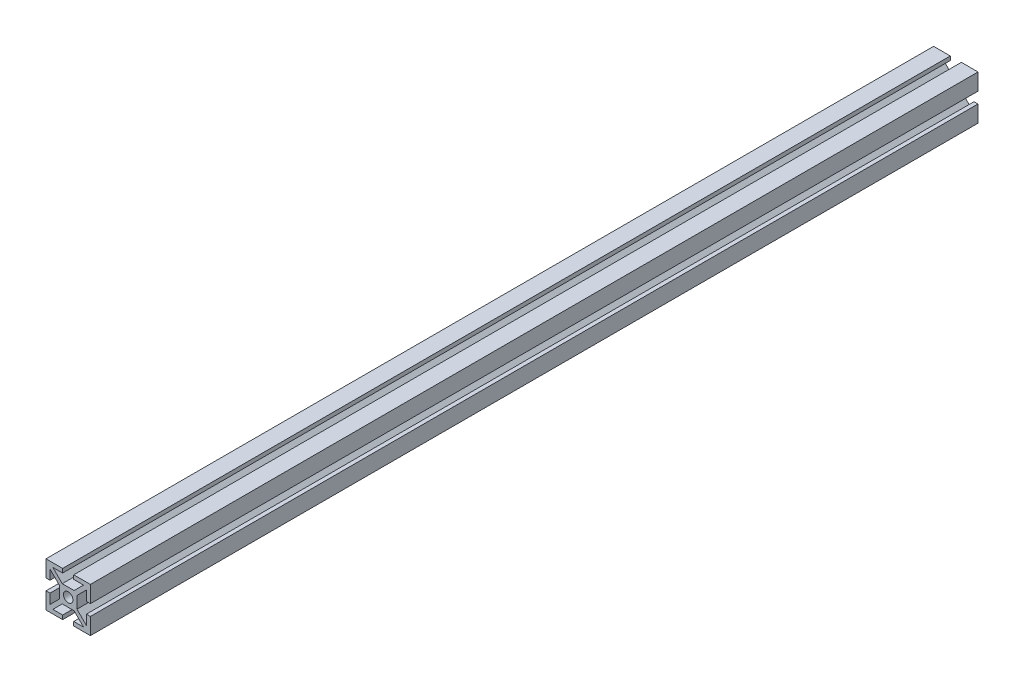
from build123d import *

# Parameters (mm, degrees)
SKETCH2_R           = 2.15
BOSS_EXTRUDE1_DEPTH = 200


with BuildPart() as part:
    # Sketch2 → Boss-Extrude1 (new body, symmetric)
    with BuildSketch(Plane.XY):
        Polygon((-2.5, 10), (-2.5, 8.2), (-6.927207794, 8.2), (-2.677207794, 3.95), (2.677207794, 3.95), (6.927207794, 8.2), (2.5, 8.2), (2.5, 10), (10, 10), (10, 2.5), (8.2, 2.5), (8.2, 6.927207794), (3.95, 2.677207794), (3.95, -2.677207794), (8.2, -6.927207794), (8.2, -2.5), (10, -2.5), (10, -10), (2.5, -10), (2.5, -8.2), (6.927207794, -8.2), (2.677207794, -3.95), (-2.677207794, -3.95), (-6.927207794, -8.2), (-2.5, -8.2), (-2.5, -10), (-10, -10), (-10, -2.5), (-8.2, -2.5), (-8.2, -6.927207794), (-3.95, -2.677207794), (-3.95, 2.677207794), (-8.2, 6.927207794), (-8.2, 2.5), (-10, 2.5), (-10, 10), align=None)
        Circle(SKETCH2_R, mode=Mode.SUBTRACT)
    extrude(amount=BOSS_EXTRUDE1_DEPTH, both=True)


solid = part.part
